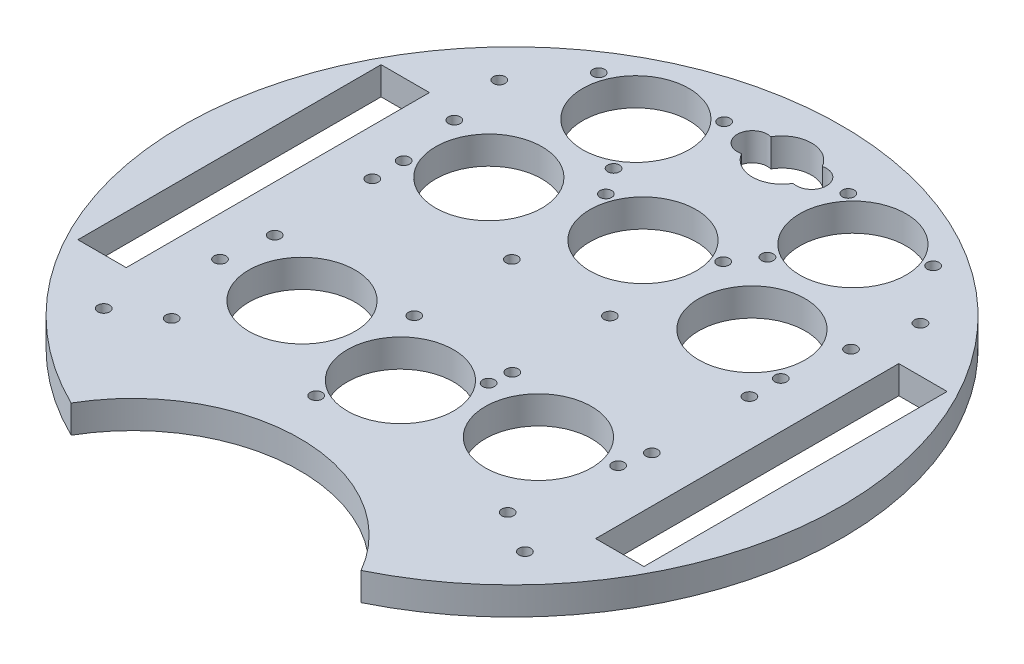
from build123d import *

# Parameters (mm, degrees)
SKETCH1_R           = 1.35
SKETCH1_R_2         = 12.095
SKETCH1_W           = 11
SKETCH1_H           = 69
BOSS_EXTRUDE2_DEPTH = 6.35


with BuildPart() as part:
    # Sketch1 → Boss-Extrude2 (new body)
    with BuildSketch(Plane(origin=(0, 0, 0), x_dir=(1, 0, 0), z_dir=(0, 1, 0))):
        with BuildLine():
            ThreePointArc((32.995567884, -67.352004425), (0, 75), (-32.995567884, -67.352004425))
            ThreePointArc((-32.995567884, -67.352004425), (0, -48.302004425), (32.995567884, -67.352004425))
        make_face()
        with Locations((-42.910067426, 11.1)):
            Circle(SKETCH1_R, mode=Mode.SUBTRACT)
        with Locations((-42.910067426, -11.1)):
            Circle(SKETCH1_R, mode=Mode.SUBTRACT)
        with Locations((-11.160067426, -11.1)):
            Circle(SKETCH1_R, mode=Mode.SUBTRACT)
        with Locations((-11.160067426, 11.1)):
            Circle(SKETCH1_R, mode=Mode.SUBTRACT)
        with Locations((11.160067426, 11.1)):
            Circle(SKETCH1_R, mode=Mode.SUBTRACT)
        with Locations((11.160067426, -11.1)):
            Circle(SKETCH1_R, mode=Mode.SUBTRACT)
        with Locations((42.910067426, -11.1)):
            Circle(SKETCH1_R, mode=Mode.SUBTRACT)
        with Locations((42.910067426, 11.1)):
            Circle(SKETCH1_R, mode=Mode.SUBTRACT)
        with Locations((26.905821676, -20.904643604)):
            Circle(SKETCH1_R_2, mode=Mode.SUBTRACT)
        with Locations((24.699796409, 52.876021886)):
            Circle(SKETCH1_R_2, mode=Mode.SUBTRACT)
        with Locations((0, 29.793589551)):
            Circle(SKETCH1_R_2, mode=Mode.SUBTRACT)
        with Locations((0, -25.409190322)):
            Circle(SKETCH1_R_2, mode=Mode.SUBTRACT)
        with Locations((29.939937248, 24.651901309)):
            Circle(SKETCH1_R_2, mode=Mode.SUBTRACT)
        with Locations((-26.905821676, -20.904643604)):
            Circle(SKETCH1_R_2, mode=Mode.SUBTRACT)
        with Locations((-29.939937248, 24.651901309)):
            Circle(SKETCH1_R_2, mode=Mode.SUBTRACT)
        with Locations((17.503855967, 40.613487823)):
            Circle(SKETCH1_R, mode=Mode.SUBTRACT)
        with Locations((14.136463763, 62.392707439)):
            Circle(SKETCH1_R, mode=Mode.SUBTRACT)
        with Locations((38.046670289, 57.776252301)):
            Circle(SKETCH1_R, mode=Mode.SUBTRACT)
        with Locations((-42.910067426, 18.234848025)):
            Circle(SKETCH1_R, mode=Mode.SUBTRACT)
        with Locations((42.910067426, 18.234848025)):
            Circle(SKETCH1_R, mode=Mode.SUBTRACT)
        with Locations((-24.699796409, 52.876021886)):
            Circle(SKETCH1_R_2, mode=Mode.SUBTRACT)
        with Locations((45.13872464, 31.997163897)):
            Circle(SKETCH1_R, mode=Mode.SUBTRACT)
        with Locations((-45.13872464, 31.997163897)):
            Circle(SKETCH1_R, mode=Mode.SUBTRACT)
        with Locations((13.346873881, 34.693819966)):
            Circle(SKETCH1_R, mode=Mode.SUBTRACT)
        with Locations((-6.55476095, -38.026099982)):
            Circle(SKETCH1_R, mode=Mode.SUBTRACT)
        with Locations((-13.346873881, 34.693819966)):
            Circle(SKETCH1_R, mode=Mode.SUBTRACT)
        with Locations((10.597026674, -15.930038136)):
            Circle(SKETCH1_R, mode=Mode.SUBTRACT)
        with Locations((-38.234289702, -39.23697625)):
            Circle(SKETCH1_R, mode=Mode.SUBTRACT)
        with Locations((-47.92720717, -45.01204963)):
            Circle(SKETCH1_R, mode=Mode.SUBTRACT)
        with Locations((-47.92720717, 45.01204963)):
            Circle(SKETCH1_R, mode=Mode.SUBTRACT)
        with Locations((47.92720717, -45.01204963)):
            Circle(SKETCH1_R, mode=Mode.SUBTRACT)
        with Locations((-38.046670289, 57.776252301)):
            Circle(SKETCH1_R, mode=Mode.SUBTRACT)
        with Locations((-14.136463763, 62.392707439)):
            Circle(SKETCH1_R, mode=Mode.SUBTRACT)
        with Locations((-17.503855967, 40.613487823)):
            Circle(SKETCH1_R, mode=Mode.SUBTRACT)
        with Locations((47.92720717, 45.01204963)):
            Circle(SKETCH1_R, mode=Mode.SUBTRACT)
        with Locations((-44.385223141, -22.074211772)):
            Circle(SKETCH1_R, mode=Mode.SUBTRACT)
        with Locations((41.601681906, -17.457756634)):
            Circle(SKETCH1_R, mode=Mode.SUBTRACT)
        with Locations((38.234289702, -39.23697625)):
            Circle(SKETCH1_R, mode=Mode.SUBTRACT)
        with Locations((58.910067426, 0.102907352)):
            Rectangle(SKETCH1_W, SKETCH1_H, mode=Mode.SUBTRACT)
        with Locations((-58.910067426, 0.102907352)):
            Rectangle(SKETCH1_W, SKETCH1_H, mode=Mode.SUBTRACT)
        with BuildLine():
            ThreePointArc((-5.853899988, 64.744946271), (0.003726822, 68.153564176), (5.857575472, 64.738461857))
            ThreePointArc((5.857575472, 64.738461857), (10.16, 61.422565207), (5.857575472, 58.106668557))
            ThreePointArc((5.857575472, 58.106668557), (0.003726822, 54.691566239), (-5.853899988, 58.100184144))
            ThreePointArc((-5.853899988, 58.100184144), (-10.167207264, 61.422565207), (-5.853899988, 64.744946271))
        make_face(mode=Mode.SUBTRACT)
    extrude(amount=BOSS_EXTRUDE2_DEPTH)


solid = part.part
